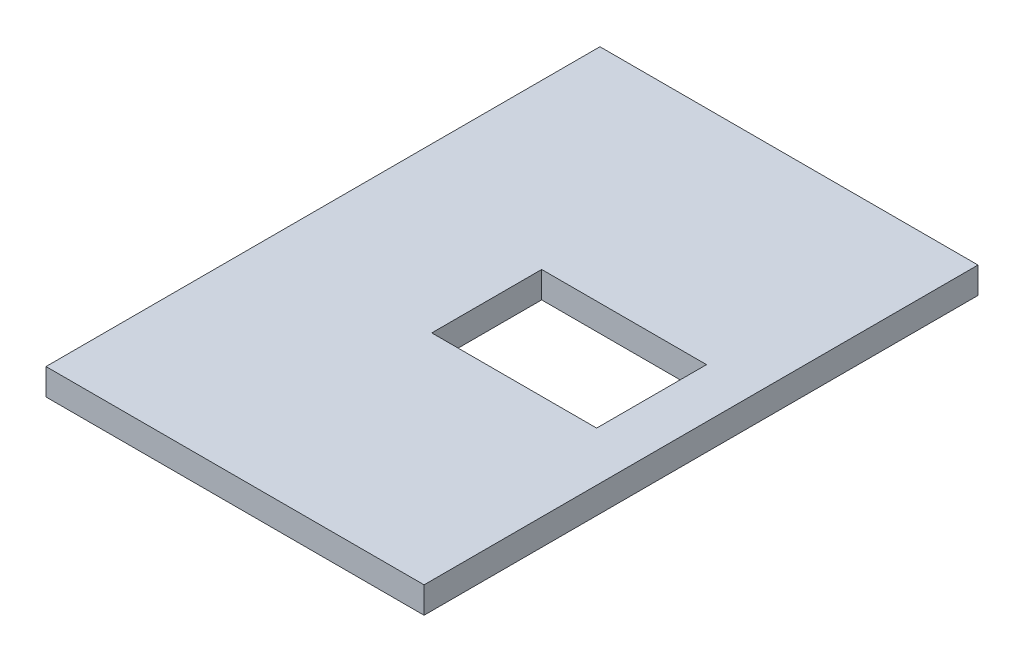
from build123d import *

# Parameters (mm, degrees)
CROQUIS1_W              = 1620
CROQUIS1_H              = 2520
CROQUIS1_W_2            = 750
CROQUIS1_H_2            = 500
SALIENTE_EXTRUIR1_DEPTH = 120
CROQUIS2_W              = 2520
CROQUIS2_H              = 120
SALIENTE_EXTRUIR2_DEPTH = 100


with BuildPart() as part:
    # Croquis1 → Saliente-Extruir1 (new body)
    with BuildSketch(Plane(origin=(0, 0, 0), x_dir=(1, 0, 0), z_dir=(0, 1, 0))):
        with Locations((-75, 0)):
            Rectangle(CROQUIS1_W, CROQUIS1_H)
        with Locations((235, 0)):
            Rectangle(CROQUIS1_W_2, CROQUIS1_H_2, mode=Mode.SUBTRACT)
    extrude(amount=SALIENTE_EXTRUIR1_DEPTH)

    # Croquis2 → Saliente-Extruir2 (add)
    with BuildSketch(Plane(origin=(735, 0, 0), x_dir=(0, 0, -1), z_dir=(1, 0, 0))):
        with Locations((0, 60)):
            Rectangle(CROQUIS2_W, CROQUIS2_H)
    extrude(amount=SALIENTE_EXTRUIR2_DEPTH)


solid = part.part
